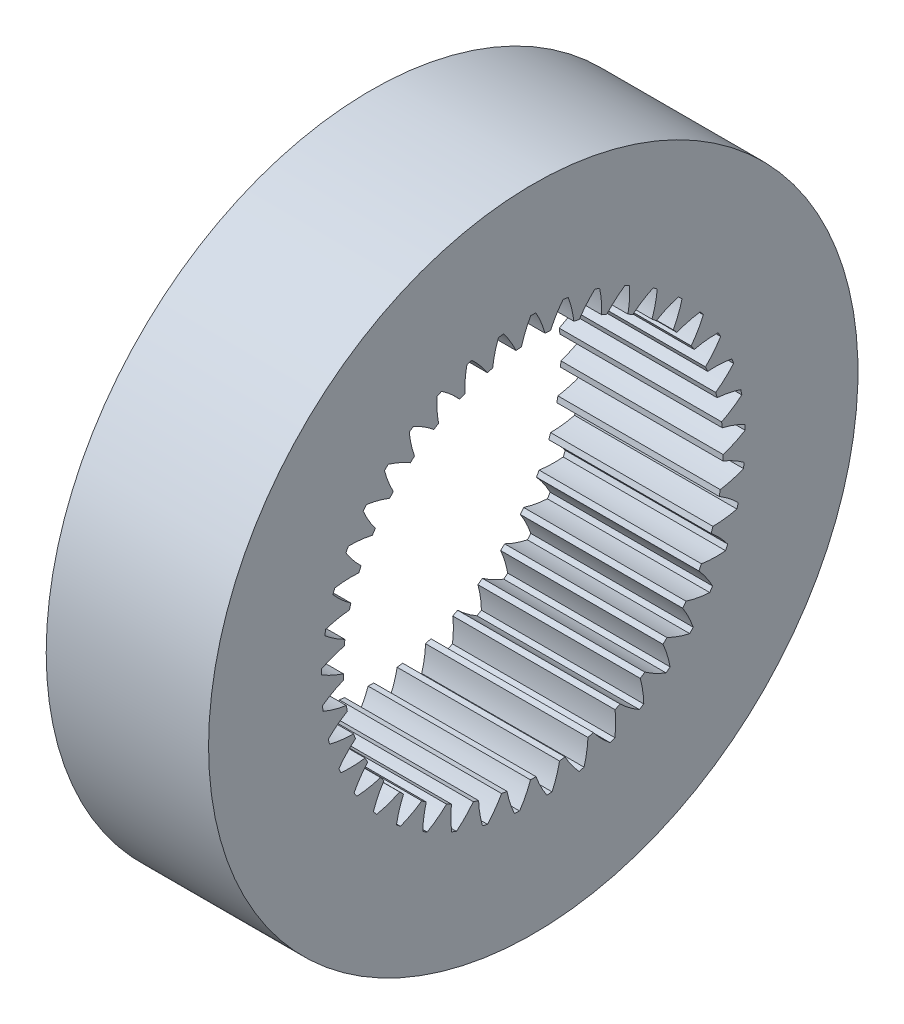
from build123d import *

# Parameters (mm, degrees)
BASPROSKE_W     = 5
BASPROSKE_H     = 4.15
TOOTHCUT_DEPTH  = 16
TEETHCUTS_COUNT = 41
TEETHCUTS_ANGLE = 351.219512195


with BuildPart() as part:
    # BasProSke → Base-Revolve (revolve)
    with BuildSketch(Plane(origin=(0, 0, 0), x_dir=(1, 0, 0), z_dir=(0, 1, 0))):
        with Locations((2.5, 7.925)):
            Rectangle(BASPROSKE_W, BASPROSKE_H)
    revolve(axis=Axis((-10, 0, 0), (1, 0, 0)))

    # TooCutSke → ToothCut (cut, through all)
    with BuildSketch(Plane(origin=(0, 0, 0), x_dir=(0, 0, -1), z_dir=(1, 0, 0))):
        with BuildLine():
            ThreePointArc((0.369965444, 5.81283844), (0.246994135, 6.178310544), (0.079249584, 6.525518792))
            ThreePointArc((0.079249584, 6.525518792), (0, 6.526), (-0.079249584, 6.525518792))
            ThreePointArc((-0.079249584, 6.525518792), (-0.246994135, 6.178310544), (-0.369965444, 5.81283844))
            ThreePointArc((-0.369965444, 5.81283844), (0, 5.8246), (0.369965444, 5.81283844))
        make_face()
    toothcut = extrude(amount=TOOTHCUT_DEPTH, mode=Mode.SUBTRACT)

    # TeethCuts: ToothCut ×41 about axis
    teethcuts_axis = Axis((-10, 0, 0), (1, 0, 0))
    for i in range(1, TEETHCUTS_COUNT):
        add(toothcut.rotate(teethcuts_axis, i * TEETHCUTS_ANGLE / (TEETHCUTS_COUNT - 1)), mode=Mode.SUBTRACT)


solid = part.part
